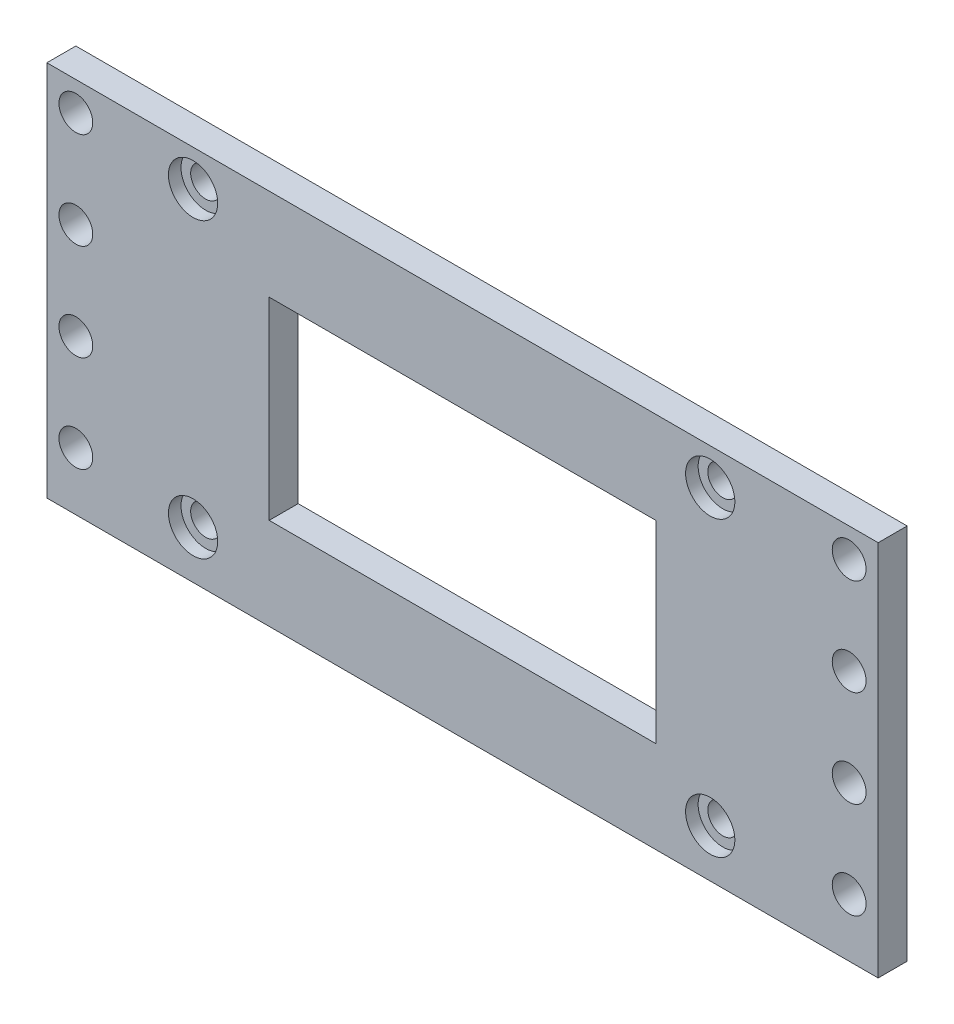
from build123d import *

# Parameters (mm, degrees)
SKETCH1_W            = 62
SKETCH1_H            = 38
SKETCH1_R            = 1.55
SKETCH1_W_2          = 40
SKETCH1_H_2          = 20
BOSS_EXTRUDE1_DEPTH  = 3
SKETCH3_W            = 86
SKETCH3_H            = 39
SKETCH3_W_2          = 62
SKETCH3_H_2          = 38
BOSS_EXTRUDE2_DEPTH  = 3
SKETCH4_R            = 1.75
CUT_EXTRUDE1_DEPTH   = 3
SKETCH5_R            = 2.55
CUT_EXTRUDE2_DEPTH   = 1.3
LPATTERN2_COUNT      = 4
LPATTERN2_PITCH      = 10
LPATTERN2_COUNT_DIR2 = 9
LPATTERN2_PITCH_DIR2 = 10


with BuildPart() as part:
    # Sketch1 → Boss-Extrude1 (new body)
    with BuildSketch(Plane.XY):
        Rectangle(SKETCH1_W, SKETCH1_H)
        with Locations((-27.873084587, 15.75)):
            Circle(SKETCH1_R, mode=Mode.SUBTRACT)
        with Locations((25.626915413, 15.75)):
            Circle(SKETCH1_R, mode=Mode.SUBTRACT)
        with Locations((-27.873084587, -14.55)):
            Circle(SKETCH1_R, mode=Mode.SUBTRACT)
        with Locations((25.626915413, -14.55)):
            Circle(SKETCH1_R, mode=Mode.SUBTRACT)
        Rectangle(SKETCH1_W_2, SKETCH1_H_2, mode=Mode.SUBTRACT)
    extrude(amount=BOSS_EXTRUDE1_DEPTH)

    # Sketch3 → Boss-Extrude2 (add)
    with BuildSketch(Plane.XY.offset(3)):
        Rectangle(SKETCH3_W, SKETCH3_H)
        Rectangle(SKETCH3_W_2, SKETCH3_H_2, mode=Mode.SUBTRACT)
    extrude(amount=-BOSS_EXTRUDE2_DEPTH)

    # Sketch4 → Cut-Extrude1 (cut)
    with BuildSketch(Plane(origin=(0, 0, 0), x_dir=(-1, 0, 0), z_dir=(0, 0, -1))):
        with Locations((-40, 16.5)):
            Circle(SKETCH4_R)
    cut_extrude1 = extrude(amount=-CUT_EXTRUDE1_DEPTH, mode=Mode.SUBTRACT)

    # Sketch5 → Cut-Extrude2 (cut)
    with BuildSketch(Plane.XY.offset(3)):
        with Locations((-27.873084587, 15.75)):
            Circle(SKETCH5_R)
        with Locations((-27.873084587, -14.55)):
            Circle(SKETCH5_R)
        with Locations((25.626915413, -14.55)):
            Circle(SKETCH5_R)
        with Locations((25.626915413, 15.75)):
            Circle(SKETCH5_R)
    extrude(amount=-CUT_EXTRUDE2_DEPTH, mode=Mode.SUBTRACT)

    # LPattern2: Cut-Extrude1 4 × 9, 28 skipped
    with Locations(*[(-j * LPATTERN2_PITCH_DIR2, -i * LPATTERN2_PITCH, 0) for i in range(LPATTERN2_COUNT) for j in range(LPATTERN2_COUNT_DIR2) if (i, j) not in ((0, 0), (0, 1), (0, 2), (0, 3), (0, 4), (0, 5), (0, 6), (0, 7), (1, 1), (1, 2), (1, 3), (1, 4), (1, 5), (1, 6), (1, 7), (2, 1), (2, 2), (2, 3), (2, 4), (2, 5), (2, 6), (2, 7), (3, 1), (3, 2), (3, 3), (3, 4), (3, 5), (3, 6), (3, 7))]):
        add(cut_extrude1, mode=Mode.SUBTRACT)


solid = part.part
